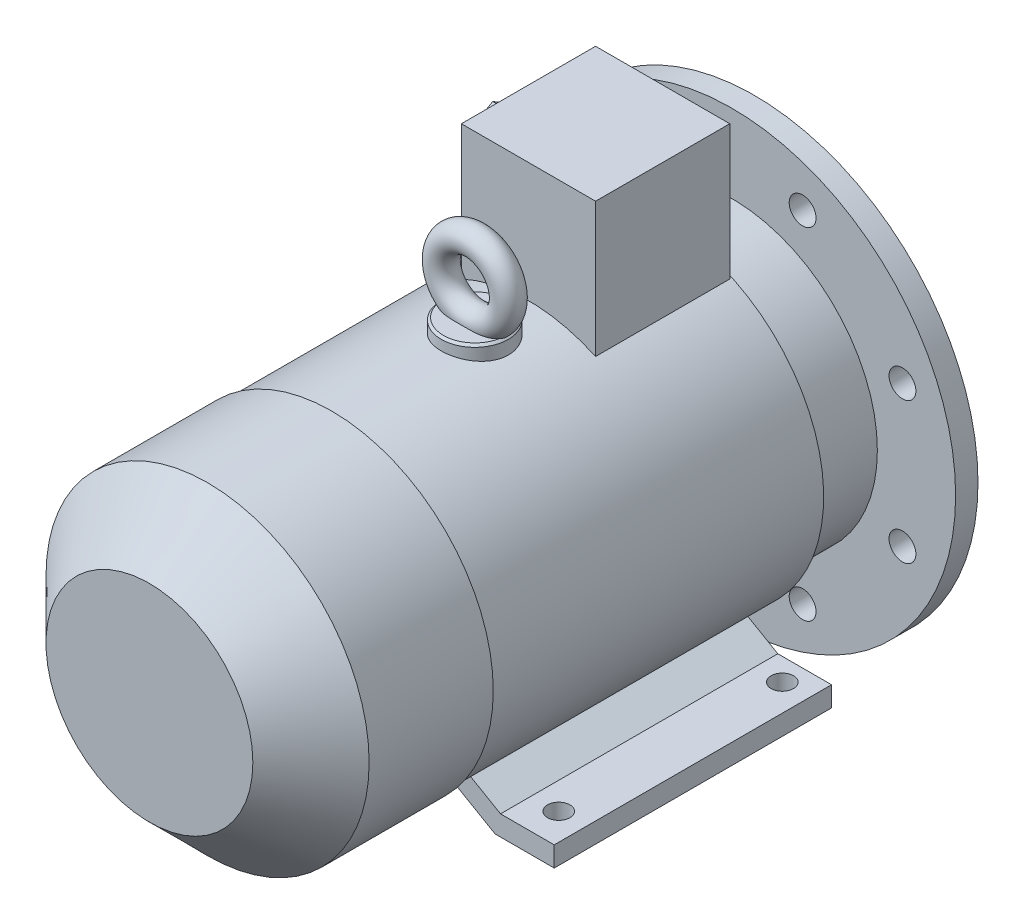
from build123d import *

# Parameters (mm, degrees)
SKETCH_1_R           = 11
EXTRUDE_1_DEPTH      = 50
SKETCH_2_W           = 6
SKETCH_2_H           = 6
EXTRUDE_2_DEPTH      = 0.1
EXTRUDE_2_DEPTH_BACK = 25
CHAMFER_1_SIZE       = 1
SKETCH_3_R           = 100
EXTRUDE_3_DEPTH      = 10
SKETCH_4_R           = 65
SKETCH_4_R_2         = 60
EXTRUDE_4_DEPTH      = 3.5
SKETCH_5_R           = 60
SKETCH_5_R_2         = 18
CUT_EXTRUDE_1_DEPTH  = 3.5
CHAMFER_2_SIZE       = 1
SKETCH_6_R           = 65
EXTRUDE_5_DEPTH      = 30
SKETCH_7_R           = 71
EXTRUDE_6_DEPTH      = 149
SKETCH_8_R           = 72.248091185
EXTRUDE_7_DEPTH      = 81.5
CHAMFER_3_SIZE       = 26
SKETCH_9_R           = 6
CUT_EXTRUDE_2_DEPTH  = 271.5
EXTRUDE_8_DEPTH      = 124
CUT_EXTRUDE_3_REACH  = 182
SKETCH_11_R          = 5
SKETCH_12_W          = 60
SKETCH_12_H          = 60
EXTRUDE_9_DEPTH      = 124.5
SKETCH_13_R          = 15
EXTRUDE_10_DEPTH     = 76.5
CHAMFER_4_SIZE       = 1
SKETCH_15_R          = 6
SKETCH_16_R          = 8
EXTRUDE_11_DEPTH     = 6
EXTRUDE_12_DEPTH     = 10
SKETCH_18_R          = 6
CUT_EXTRUDE_4_DEPTH  = 10


with BuildPart() as part:
    # Эскиз1 → Вытянуть1 (new body)
    with BuildSketch(Plane.XY):
        Circle(SKETCH_1_R)
    extrude(amount=EXTRUDE_1_DEPTH)

    # Эскиз2 → Вытянуть2 (add, two sides)
    with BuildSketch(Plane(origin=(0, 0, 0), x_dir=(-1, 0, 0), z_dir=(0, 0, -1))) as extrude_2_sk:
        with Locations((0, 10.5)):
            Rectangle(SKETCH_2_W, SKETCH_2_H)
    extrude(amount=EXTRUDE_2_DEPTH)
    extrude(extrude_2_sk.sketch, amount=-EXTRUDE_2_DEPTH_BACK)

    # Фаска1
    chamfer_1_edges = [part.edges().sort_by_distance(p)[0] for p in [
        (-6.633249581, -8.774964387, 0),
    ]]
    chamfer(chamfer_1_edges, length=CHAMFER_1_SIZE)

    # Эскиз3 → Вытянуть3 (add)
    with BuildSketch(Plane.XY.offset(50)):
        Circle(SKETCH_3_R)
    extrude(amount=EXTRUDE_3_DEPTH)

    # Эскиз4 → Вытянуть4 (add)
    with BuildSketch(Plane(origin=(0, 0, 50), x_dir=(-1, 0, 0), z_dir=(0, 0, -1))):
        with Locations(Location((0, 0, 0), (0, 0, 180))):  # turned: the seam where the file's is
            Circle(SKETCH_4_R)
        Circle(SKETCH_4_R_2, mode=Mode.SUBTRACT)
    extrude(amount=EXTRUDE_4_DEPTH)

    # Эскиз5 → Вырез-Вытянуть1 (cut)
    with BuildSketch(Plane(origin=(0, 0, 50), x_dir=(-1, 0, 0), z_dir=(0, 0, -1))):
        Circle(SKETCH_5_R)
        Circle(SKETCH_5_R_2, mode=Mode.SUBTRACT)
    extrude(amount=-CUT_EXTRUDE_1_DEPTH, mode=Mode.SUBTRACT)

    # Фаска2
    chamfer_2_edges = [part.edges().sort_by_distance(p)[0] for p in [
        (-65, 0, 46.5),
        (18, 0, 50),
    ]]
    chamfer(chamfer_2_edges, length=CHAMFER_2_SIZE)

    # Эскиз6 → Вытянуть5 (add)
    with BuildSketch(Plane.XY.offset(60)):
        Circle(SKETCH_6_R)
    extrude(amount=EXTRUDE_5_DEPTH)

    # Эскиз7 → Вытянуть6 (add)
    with BuildSketch(Plane.XY.offset(90)):
        Circle(SKETCH_7_R)
    extrude(amount=EXTRUDE_6_DEPTH)

    # Эскиз8 → Вытянуть7 (add)
    with BuildSketch(Plane.XY.offset(239)):
        Circle(SKETCH_8_R)
    extrude(amount=EXTRUDE_7_DEPTH)

    # Фаска3
    chamfer_3_edges = [part.edges().sort_by_distance(p)[0] for p in [
        (-72.248091185, 0, 320.5),
    ]]
    chamfer(chamfer_3_edges, length=CHAMFER_3_SIZE)

    # Эскиз9 → Вырез-Вытянуть2 (cut, through all)
    with BuildSketch(Plane(origin=(0, 0, 50), x_dir=(-1, 0, 0), z_dir=(0, 0, -1))):
        with Locations((-31.57138317, 76.220061432)):
            Circle(SKETCH_9_R)
        with Locations((31.57138317, 76.220061432)):
            Circle(SKETCH_9_R)
        with Locations((76.220061432, 31.57138317)):
            Circle(SKETCH_9_R)
        with Locations((76.220061432, -31.57138317)):
            Circle(SKETCH_9_R)
        with Locations((31.57138317, -76.220061432)):
            Circle(SKETCH_9_R)
        with Locations((-31.57138317, -76.220061432)):
            Circle(SKETCH_9_R)
        with Locations((-76.220061432, -31.57138317)):
            Circle(SKETCH_9_R)
        with Locations((-76.220061432, 31.57138317)):
            Circle(SKETCH_9_R)
    extrude(amount=-CUT_EXTRUDE_2_DEPTH, mode=Mode.SUBTRACT)

    # Эскиз10 → Вытянуть8 (add)
    with BuildSketch(Plane(origin=(0, 0, 90), x_dir=(-1, 0, 0), z_dir=(0, 0, -1))):
        Polygon((-74.5, -80), (-48.088457268, -80), (-11.515477308, -58.884580175), (-23.295059446, -55.293220248), (-50.5, -71), (-74.5, -71), align=None)
        Polygon((74.5, -71), (74.5, -80), (48.088457268, -80), (11.515477308, -58.884580175), (23.295059446, -55.293220248), (50.5, -71), align=None)
    extrude(amount=-EXTRUDE_8_DEPTH)

    # Эскиз11 → Вырез-Вытянуть3 (cut, up to next)
    with BuildSketch(Plane.XZ.offset(80), mode=Mode.PRIVATE) as cut_extrude_3_sk1:
        with Locations(Location((-62.5, 100, 0), (0, 0, 270))):  # turned: the seam where the file's is
            Circle(SKETCH_11_R)
    cut_extrude_3_tool1 = extrude(cut_extrude_3_sk1.sketch, amount=-CUT_EXTRUDE_3_REACH, mode=Mode.PRIVATE) & part.part
    add(cut_extrude_3_tool1.solids().sort_by_distance((-62.5, -80, 100))[0], mode=Mode.SUBTRACT)
    # Эскиз11 → Вырез-Вытянуть3 (cut, up to next)
    with BuildSketch(Plane.XZ.offset(80), mode=Mode.PRIVATE) as cut_extrude_3_sk2:
        with Locations(Location((62.5, 100, 0), (0, 0, 270))):  # turned: the seam where the file's is
            Circle(SKETCH_11_R)
    cut_extrude_3_tool2 = extrude(cut_extrude_3_sk2.sketch, amount=-CUT_EXTRUDE_3_REACH, mode=Mode.PRIVATE) & part.part
    add(cut_extrude_3_tool2.solids().sort_by_distance((62.5, -80, 100))[0], mode=Mode.SUBTRACT)
    # Эскиз11 → Вырез-Вытянуть3 (cut, up to next)
    with BuildSketch(Plane.XZ.offset(80), mode=Mode.PRIVATE) as cut_extrude_3_sk3:
        with Locations(Location((-62.5, 200, 0), (0, 0, 270))):  # turned: the seam where the file's is
            Circle(SKETCH_11_R)
    cut_extrude_3_tool3 = extrude(cut_extrude_3_sk3.sketch, amount=-CUT_EXTRUDE_3_REACH, mode=Mode.PRIVATE) & part.part
    add(cut_extrude_3_tool3.solids().sort_by_distance((-62.5, -80, 200))[0], mode=Mode.SUBTRACT)
    # Эскиз11 → Вырез-Вытянуть3 (cut, up to next)
    with BuildSketch(Plane.XZ.offset(80), mode=Mode.PRIVATE) as cut_extrude_3_sk4:
        with Locations(Location((62.5, 200, 0), (0, 0, 270))):  # turned: the seam where the file's is
            Circle(SKETCH_11_R)
    cut_extrude_3_tool4 = extrude(cut_extrude_3_sk4.sketch, amount=-CUT_EXTRUDE_3_REACH, mode=Mode.PRIVATE) & part.part
    add(cut_extrude_3_tool4.solids().sort_by_distance((62.5, -80, 200))[0], mode=Mode.SUBTRACT)

    # Эскиз12 → Вытянуть9 (add)
    with BuildSketch(Plane(origin=(0, 0, 0), x_dir=(1, 0, 0), z_dir=(0, 1, 0))):
        with Locations((0, -121)):
            Rectangle(SKETCH_12_W, SKETCH_12_H)
    extrude(amount=EXTRUDE_9_DEPTH)

    # Эскиз13 → Вытянуть10 (add)
    with BuildSketch(Plane(origin=(0, 0, 0), x_dir=(1, 0, 0), z_dir=(0, 1, 0))):
        with Locations(Location((0, -175, 0), (0, 0, 90))):  # turned: the seam where the file's is
            Circle(SKETCH_13_R)
    extrude(amount=EXTRUDE_10_DEPTH)

    # Фаска4
    chamfer_4_edges = [part.edges().sort_by_distance(p)[0] for p in [
        (0, 76.5, 190),
    ]]
    chamfer(chamfer_4_edges, length=CHAMFER_4_SIZE)

    # По траектории1: sweep along a path in Эскиз14
    with BuildLine(Plane.XY.offset(175)) as sweep_1_path:
        CenterArc((0, 91.5), 15, 0, 360)
    # Эскиз15 → По траектории1 (sweep)
    with BuildSketch(Plane(origin=(0, 0, 0), x_dir=(0, 0, -1), z_dir=(1, 0, 0))):
        with Locations((-175, 106.5)):
            Circle(SKETCH_15_R)
    sweep(path=sweep_1_path.line)

    # Эскиз16 → Вытянуть11 (add)
    with BuildSketch(Plane.ZY.offset(30)):
        with Locations(Location((121, 94.5, 0), (0, 0, 180))):  # turned: the seam where the file's is
            Circle(SKETCH_16_R)
    extrude(amount=EXTRUDE_11_DEPTH)

    # Эскиз17 → Вытянуть12 (add)
    with BuildSketch(Plane.ZY.offset(36)):
        Polygon((121, 110.088457268), (107.5, 102.294228634), (107.5, 86.705771366), (121, 78.911542732), (134.5, 86.705771366), (134.5, 102.294228634), align=None)
    extrude(amount=EXTRUDE_12_DEPTH)

    # Эскиз18 → Вырез-Вытянуть4 (cut)
    with BuildSketch(Plane.ZY.offset(46)):
        with Locations((121, 94.5)):
            Circle(SKETCH_18_R)
    extrude(amount=-CUT_EXTRUDE_4_DEPTH, mode=Mode.SUBTRACT)


solid = part.part
